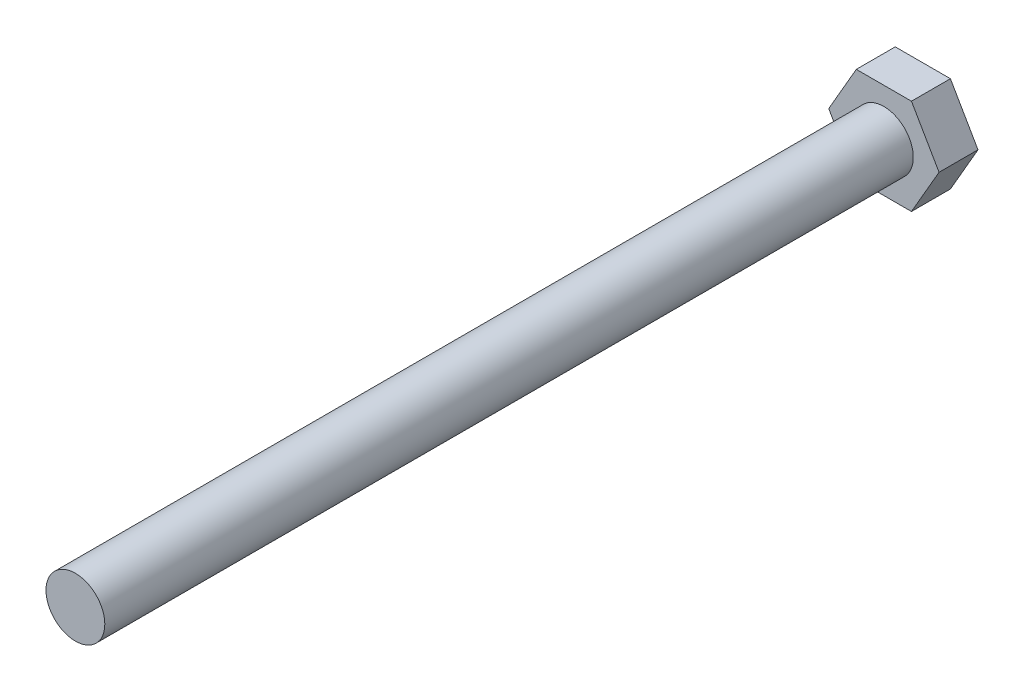
from build123d import *

# Parameters (mm, degrees)
BASE_EXTRUDE_DEPTH  = 5.3
SKETCH2_R           = 4
BOSS_EXTRUDE1_DEPTH = 110


with BuildPart() as part:
    # Sketch1 → Base-Extrude (new body)
    with BuildSketch(Plane.XY):
        Polygon((7.505553499, 0), (3.75277675, 6.5), (-3.75277675, 6.5), (-7.505553499, 0), (-3.75277675, -6.5), (3.75277675, -6.5), align=None)
    extrude(amount=BASE_EXTRUDE_DEPTH)

    # Sketch2 → Boss-Extrude1 (add)
    with BuildSketch(Plane.XY.offset(5.3)):
        Circle(SKETCH2_R)
    extrude(amount=BOSS_EXTRUDE1_DEPTH)


solid = part.part
